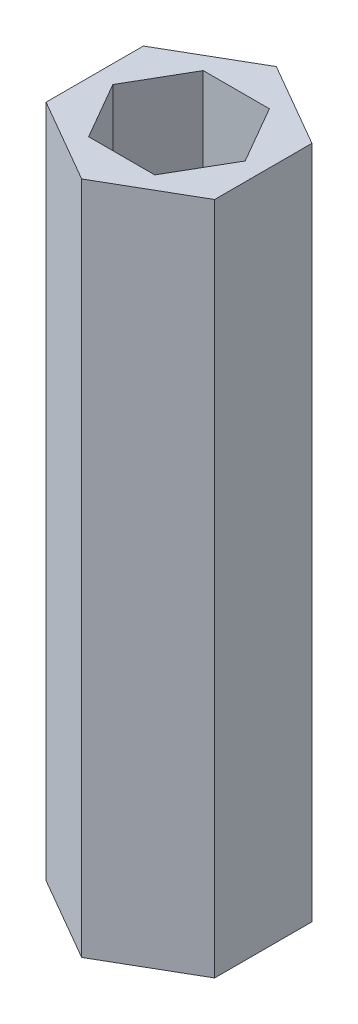
from build123d import *

# Parameters (mm, degrees)
BOSS_EXTRUDE1_DEPTH = 76.2


with BuildPart() as part:
    # Sketch1 → Boss-Extrude1 (new body)
    with BuildSketch(Plane(origin=(0, 0, 0), x_dir=(1, 0, 0), z_dir=(0, 1, 0))):
        Polygon((0, -10.998522628), (9.525, -5.499261314), (9.525, 5.499261314), (0, 10.998522628), (-9.525, 5.499261314), (-9.525, -5.499261314), align=None)
        Polygon((3.739497694, 6.477), (-3.739497694, 6.477), (-7.478995387, 0), (-3.739497694, -6.477), (3.739497694, -6.477), (7.478995387, 0), align=None, mode=Mode.SUBTRACT)
    extrude(amount=BOSS_EXTRUDE1_DEPTH)


solid = part.part
